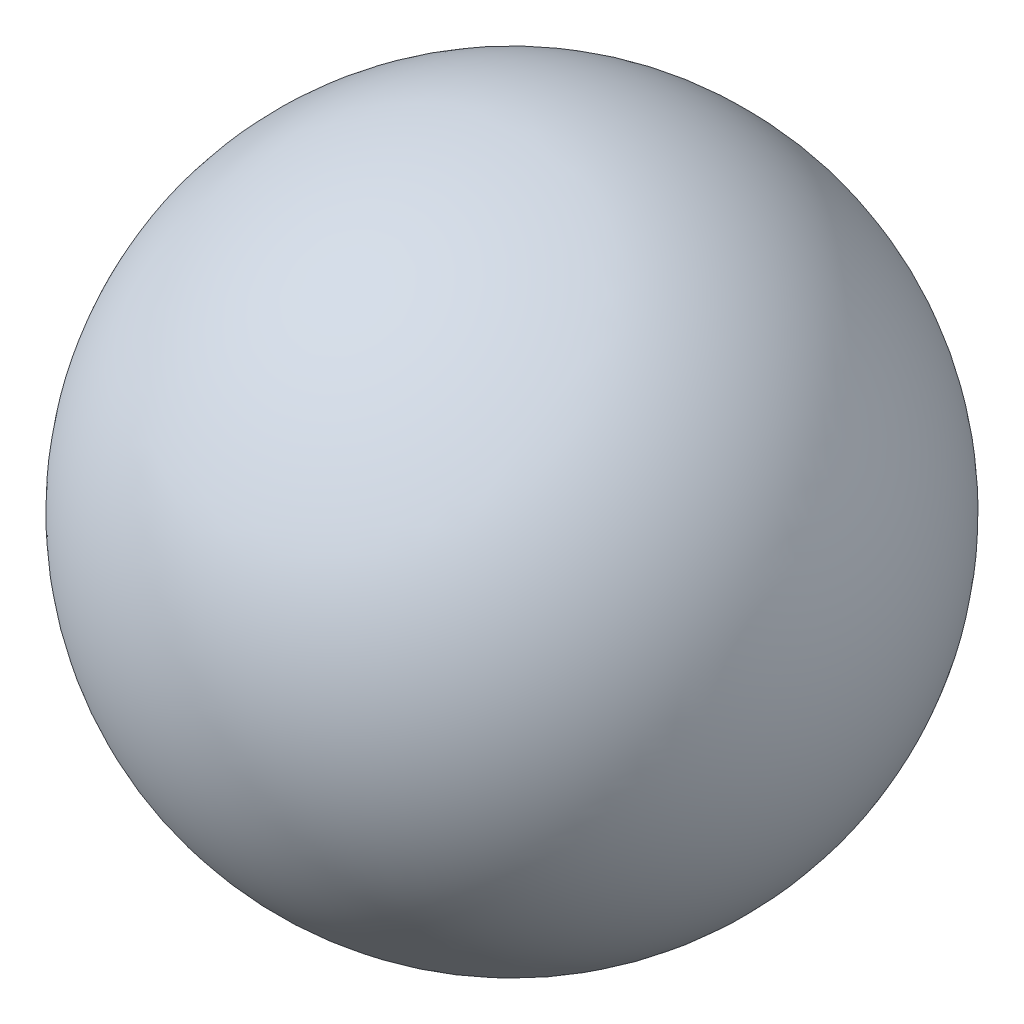
from build123d import *


with BuildPart() as part:
    # Sketch1 → Revolve3 (revolve)
    with BuildSketch(Plane.XY):
        with BuildLine():
            Line((-6, 0), (6, 0))
            ThreePointArc((6, 0), (0, 6), (-6, 0))
        make_face()
    revolve(axis=Axis((-6.173115056, 0, 0), (1, 0, 0)))


solid = part.part
